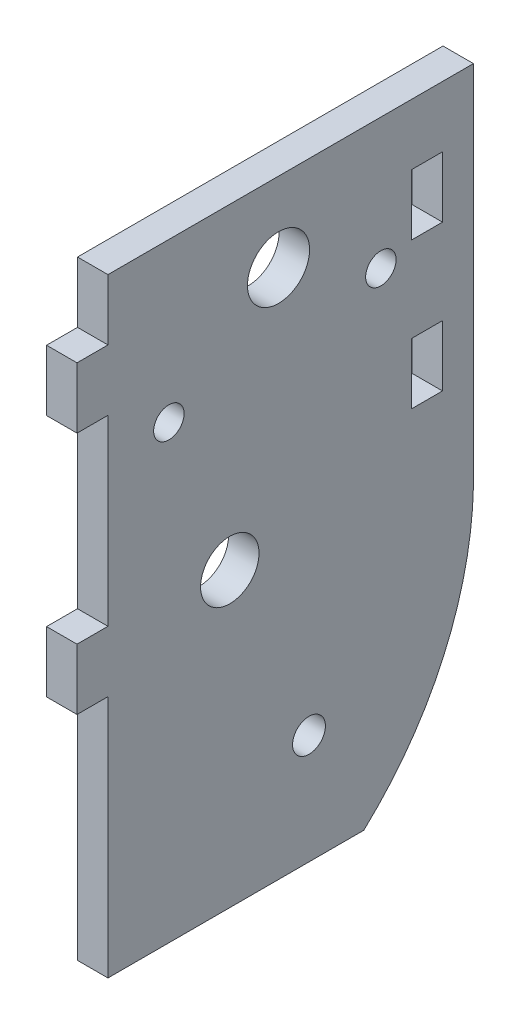
from build123d import *

# Parameters (mm, degrees)
SKETCH1_W                           = 38.1
SKETCH1_H                           = 63.5
MAIN_BODY_DEPTH                     = 3.175
SKETCH2_W                           = 3.2258
SKETCH2_H                           = 6.35
TABS_DEPTH                          = 3.175
SKETCH5_R                           = 1.7145
MOTOR_CUT_DEPTH                     = 4.175
SKETCH6_R                           = 3.2385
CUT_FOR_AXLE_DEPTH                  = 4.175
ROUND_OFF_BACK_CORNER_DEPTH         = 4.175
SKETCH9_W                           = 3.2258
SKETCH9_H                           = 6.35
CUT_FOR_TABS_DEPTH                  = 4.175
SKETCH10_R                          = 3.048
CUT_FOR_SCREW_ACCESS_DEPTH          = 4.175
SKETCH11_R                          = 1.5875
CUT_FOR_BRACKET_SCREW_DEPTH         = 4.175
SKETCH12_R                          = 1.5875
CUT_FOR_BASIC_TILT_LOCK_SCREW_DEPTH = 4.175


with BuildPart() as part:
    # Sketch1 → main body (new body)
    with BuildSketch(Plane(origin=(0, 0, 0), x_dir=(0, 0, -1), z_dir=(1, 0, 0))):
        Rectangle(SKETCH1_W, SKETCH1_H)
    extrude(amount=MAIN_BODY_DEPTH)

    # Sketch2 → tabs (add)
    with BuildSketch(Plane(origin=(3.175, 0, 0), x_dir=(0, 0, -1), z_dir=(1, 0, 0))):
        with Locations((-20.6629, 22.225)):
            Rectangle(SKETCH2_W, SKETCH2_H)
        with Locations((-20.6629, -3.175)):
            Rectangle(SKETCH2_W, SKETCH2_H)
    extrude(amount=-TABS_DEPTH)

    # Sketch5 → motor cut (cut, through all)
    with BuildSketch(Plane(origin=(3.175, 0, 0), x_dir=(0, 0, -1), z_dir=(1, 0, 0))):
        with Locations((1.905, -20.32)):
            Circle(SKETCH5_R)
    extrude(amount=-MOTOR_CUT_DEPTH, mode=Mode.SUBTRACT)

    # Sketch6 → cut for axle (cut, through all)
    with BuildSketch(Plane(origin=(3.175, 0, 0), x_dir=(0, 0, -1), z_dir=(1, 0, 0))):
        with Locations((-1.27, 23.495)):
            Circle(SKETCH6_R)
    extrude(amount=-CUT_FOR_AXLE_DEPTH, mode=Mode.SUBTRACT)

    # Sketch7 → round off back corner (cut, through all)
    with BuildSketch(Plane(origin=(3.175, 0, 0), x_dir=(0, 0, -1), z_dir=(1, 0, 0))):
        with BuildLine():
            Line((19.05, -31.75), (19.05, -6.35))
            ThreePointArc((19.05, -6.35), (15.925359096, -20.215661593), (7.62, -31.75))
            Line((7.62, -31.75), (19.05, -31.75))
        make_face()
    extrude(amount=-ROUND_OFF_BACK_CORNER_DEPTH, mode=Mode.SUBTRACT)

    # Sketch9 → cut for tabs (cut, through all)
    with BuildSketch(Plane(origin=(3.175, 0, 0), x_dir=(0, 0, -1), z_dir=(1, 0, 0))):
        with Locations((14.2113, 22.225)):
            Rectangle(SKETCH9_W, SKETCH9_H)
        with Locations((14.2113, 6.985)):
            Rectangle(SKETCH9_W, SKETCH9_H)
    extrude(amount=-CUT_FOR_TABS_DEPTH, mode=Mode.SUBTRACT)

    # Sketch10 → cut for screw access (cut, through all)
    with BuildSketch(Plane.ZY):
        with Locations((6.35, -1.27)):
            Circle(SKETCH10_R)
    extrude(amount=-CUT_FOR_SCREW_ACCESS_DEPTH, mode=Mode.SUBTRACT)

    # Sketch11 → cut for bracket screw (cut, through all)
    with BuildSketch(Plane.ZY):
        with Locations((12.7, 15.24)):
            Circle(SKETCH11_R)
    extrude(amount=-CUT_FOR_BRACKET_SCREW_DEPTH, mode=Mode.SUBTRACT)

    # Sketch12 → cut for basic tilt lock screw (cut, through all)
    with BuildSketch(Plane.ZY):
        with Locations((-9.398, 18.0975)):
            Circle(SKETCH12_R)
    extrude(amount=-CUT_FOR_BASIC_TILT_LOCK_SCREW_DEPTH, mode=Mode.SUBTRACT)


solid = part.part
